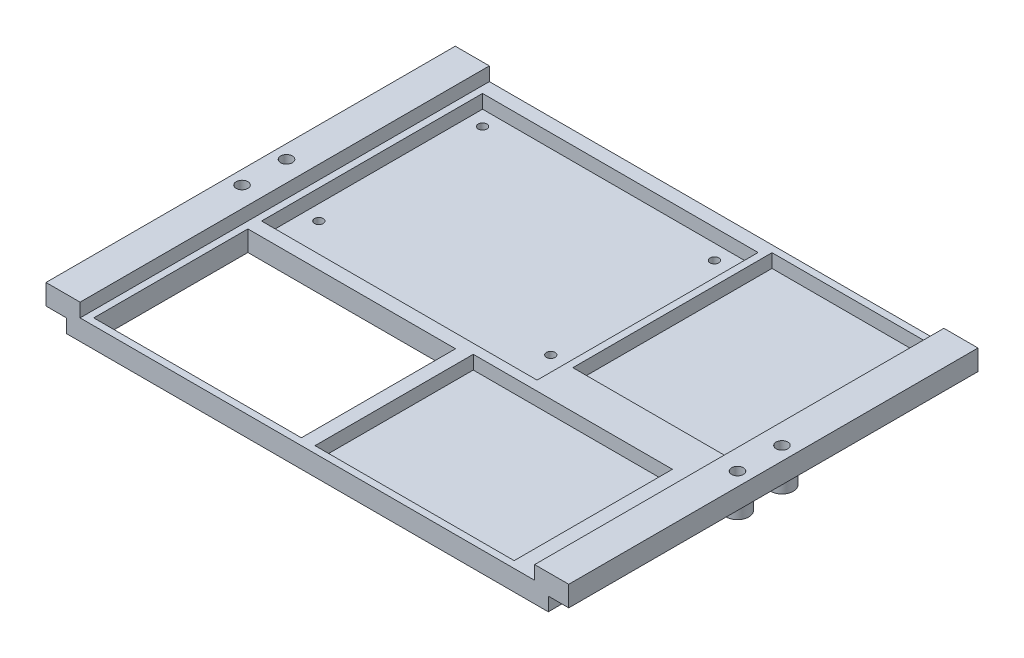
from build123d import *

# Parameters (mm, degrees)
PLATEFRAME_DEPTH          = 150
SKETCH3_R                 = 2.15
HOLESUPPORT_DEPTH         = 7.5
SKETCH4_R                 = 4.15
SKETCH4_R_2               = 2.15
CYLINDRICALSUPPORTS_DEPTH = 12.5
SKETCH5_W                 = 101
SKETCH5_H                 = 81
SKETCH5_W_2               = 58
SKETCH5_H_2               = 73
SKETCH5_W_3               = 73
SKETCH5_H_3               = 58
ITEMLAYOUT_DEPTH          = 5
SKETCH6_R                 = 1.6
JETSONBASEHOLES_DEPTH     = 2.5
SKETCH7_W                 = 76.1
SKETCH7_H                 = 56.5
OPENHOLE_DEPTH            = 8.5


with BuildPart() as part:
    # Sketch2 → PlateFrame (new body)
    with BuildSketch(Plane.XY):
        Polygon((179.1, 12.5), (191.6, 12.5), (191.6, 5), (184.1, 5), (184.1, 0), (7.5, 0), (7.5, 5), (0, 5), (0, 12.5), (12.5, 12.5), (12.5, 7.5), (179.1, 7.5), align=None)
    extrude(amount=PLATEFRAME_DEPTH)

    # Sketch3 → HoleSupport (cut)
    with BuildSketch(Plane(origin=(0, 12.5, 0), x_dir=(1, 0, 0), z_dir=(0, 1, 0))):
        with Locations((5, -66.85)):
            Circle(SKETCH3_R)
        with Locations((5, -83.15)):
            Circle(SKETCH3_R)
        with Locations((186.6, -66.85)):
            Circle(SKETCH3_R)
        with Locations((186.6, -83.15)):
            Circle(SKETCH3_R)
    extrude(amount=-HOLESUPPORT_DEPTH, mode=Mode.SUBTRACT)

    # Sketch4 → CylindricalSupports (add)
    with BuildSketch(Plane(origin=(0, 12.5, 0), x_dir=(1, 0, 0), z_dir=(0, 1, 0))):
        with Locations((186.6, -66.85)):
            Circle(SKETCH4_R)
        with Locations((186.6, -66.85)):
            Circle(SKETCH4_R_2, mode=Mode.SUBTRACT)
        with Locations((186.6, -83.15)):
            Circle(SKETCH4_R)
        with Locations((186.6, -83.15)):
            Circle(SKETCH4_R_2, mode=Mode.SUBTRACT)
        with Locations((5, -66.85)):
            Circle(SKETCH4_R)
        with Locations((5, -66.85)):
            Circle(SKETCH4_R_2, mode=Mode.SUBTRACT)
        with Locations((5, -83.15)):
            Circle(SKETCH4_R)
        with Locations((5, -83.15)):
            Circle(SKETCH4_R_2, mode=Mode.SUBTRACT)
    extrude(amount=-CYLINDRICALSUPPORTS_DEPTH)

    # Sketch5 → ItemLayout (cut)
    with BuildSketch(Plane(origin=(0, 7.5, 0), x_dir=(1, 0, 0), z_dir=(0, 1, 0))):
        with Locations((65.5, -45.5)):
            Rectangle(SKETCH5_W, SKETCH5_H)
        with Locations((147.6, -39)):
            Rectangle(SKETCH5_W_2, SKETCH5_H_2)
        with Locations((132.6, -118.5)):
            Rectangle(SKETCH5_W_3, SKETCH5_H_3)
    extrude(amount=-ITEMLAYOUT_DEPTH, mode=Mode.SUBTRACT)

    # Sketch6 → JetsonBaseHoles (cut)
    with BuildSketch(Plane(origin=(0, 2.5, 0), x_dir=(1, 0, 0), z_dir=(0, 1, 0))):
        with Locations((20.5, -10.5)):
            Circle(SKETCH6_R)
        with Locations((20.5, -70.5)):
            Circle(SKETCH6_R)
        with Locations((105.5, -70.5)):
            Circle(SKETCH6_R)
        with Locations((105.5, -10.5)):
            Circle(SKETCH6_R)
    extrude(amount=-JETSONBASEHOLES_DEPTH, mode=Mode.SUBTRACT)

    # Sketch7 → OpenHole (cut, through all)
    with BuildSketch(Plane(origin=(0, 7.5, 0), x_dir=(1, 0, 0), z_dir=(0, 1, 0))):
        with Locations((53.05, -119.25)):
            Rectangle(SKETCH7_W, SKETCH7_H)
    extrude(amount=-OPENHOLE_DEPTH, mode=Mode.SUBTRACT)


solid = part.part
